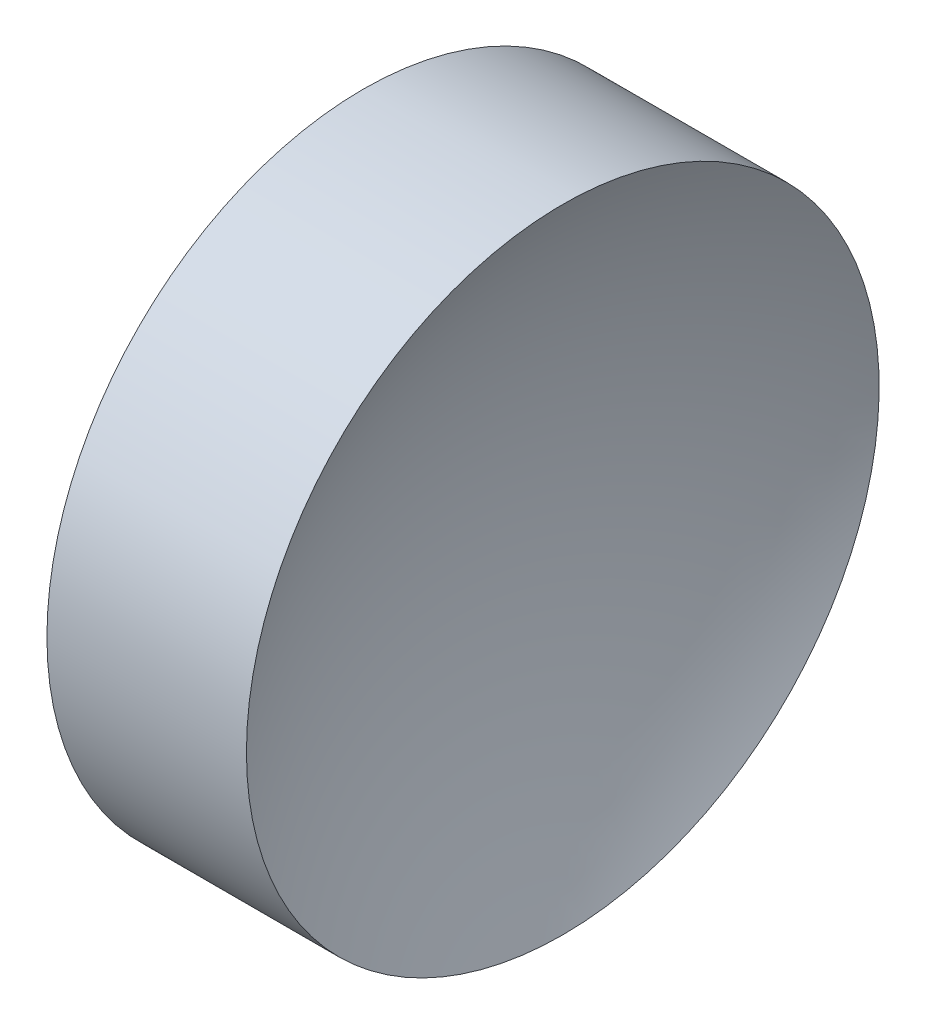
from build123d import *


with BuildPart() as part:
    # 草图1 → 旋转1 (revolve)
    with BuildSketch(Plane.XY, mode=Mode.PRIVATE) as revolve_1_sk:
        with BuildLine():
            Line((121.574877167, 65.222602873), (118.574877167, 65.222602873))
            ThreePointArc((118.574877167, 65.222602873), (116.953947756, 78.123592193), (112.191923172, 90.222602873))
            Line((112.191923172, 90.222602873), (120.074877167, 90.222602873))
            Line((120.074877167, 90.222602873), (127.957831163, 90.222602873))
            ThreePointArc((127.957831163, 90.222602873), (123.195806578, 78.123592193), (121.574877167, 65.222602873))
        make_face()
    revolve(revolve_1_sk.sketch.rotate(Axis((106.124652785, 65.222602873, 0), (1, 0, 0)), 90), axis=Axis((106.124652785, 65.222602873, 0), (1, 0, 0)))  # turned: the seam where the file's is


solid = part.part
